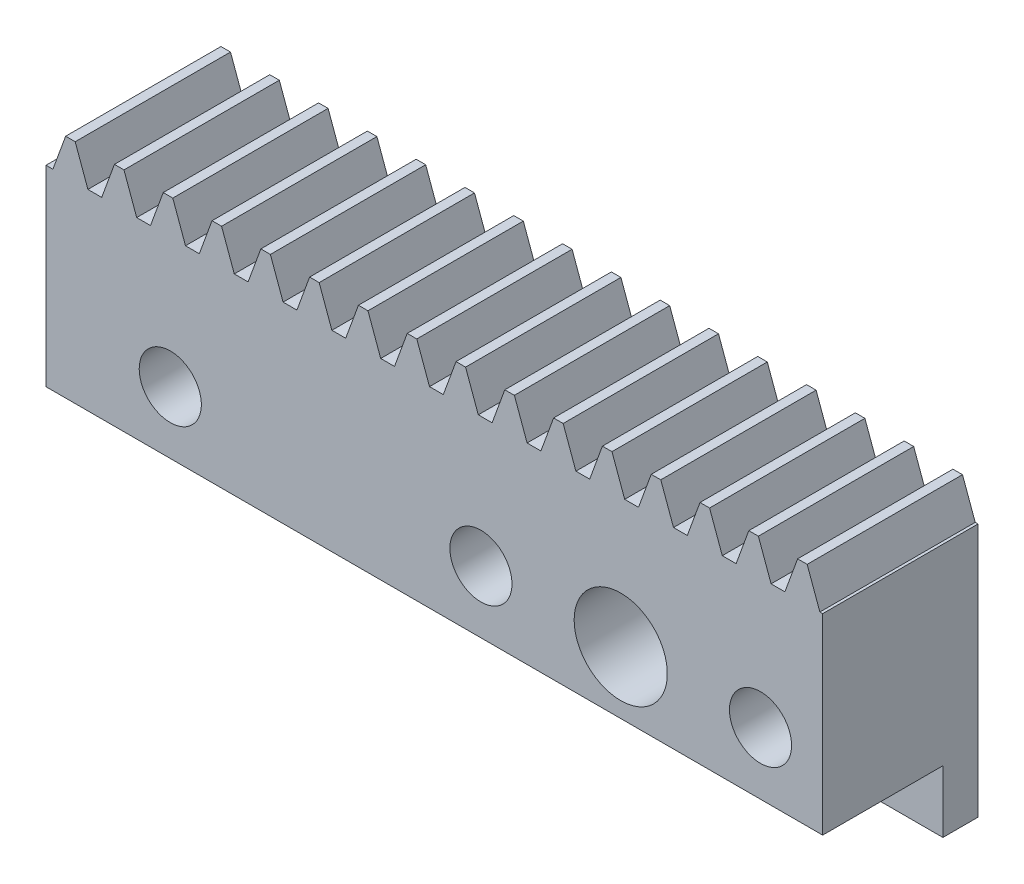
from build123d import *

# Parameters (mm, degrees)
BLANKSKE_W          = 25
BLANKSKE_H          = 7.3
BLANK_DEPTH         = 4
TOOTHCUTSIM_DEPTH   = 27.349383294
TEETHCUTS_COUNT     = 17
TEETHCUTS_PITCH     = 1.570796325
SKETCH4_W           = 25
SKETCH4_H           = 1.13
BOSS_EXTRUDE1_DEPTH = 2
BOSS_EXTRUDE2_DEPTH = 1
CUT_EXTRUDE1_DEPTH  = 27.519615382


with BuildPart() as part:
    # BlankSke → Blank (new body)
    with BuildSketch(Plane.XY):
        with Locations((12.5, 3.65)):
            Rectangle(BLANKSKE_W, BLANKSKE_H)
    extrude(amount=-BLANK_DEPTH)

    # TooCutSkeSim → ToothCutSim (cut, through all)
    with BuildSketch(Plane.XY):
        Polygon((0.222217685, 6.175), (-0.222217685, 6.175), (-0.640929042, 7.3254), (0.640929042, 7.3254), align=None)
    toothcutsim = extrude(amount=-TOOTHCUTSIM_DEPTH, mode=Mode.SUBTRACT)

    # TeethCuts: ToothCutSim ×17
    with Locations(*[(i * TEETHCUTS_PITCH, 0, 0) for i in range(1, TEETHCUTS_COUNT)]):
        add(toothcutsim, mode=Mode.SUBTRACT)

    # Sketch4 → Boss-Extrude1 (add)
    with BuildSketch(Plane.XZ):
        with Locations((12.5, -3.435)):
            Rectangle(SKETCH4_W, SKETCH4_H)
    extrude(amount=BOSS_EXTRUDE1_DEPTH)

    # Sketch7 → Boss-Extrude2 (add)
    with BuildSketch(Plane.XY):
        Polygon((25, 6.175), (24.910523515, 6.175), (24.501057002, 7.3), (24.193629073, 7.3), (23.78416256, 6.175), (23.33972719, 6.175), (22.930260677, 7.3), (22.622832748, 7.3), (22.213366235, 6.175), (21.768930865, 6.175), (21.359464352, 7.3), (21.052036423, 7.3), (20.64256991, 6.175), (20.19813454, 6.175), (19.788668027, 7.3), (19.481240098, 7.3), (19.071773585, 6.175), (18.627338215, 6.175), (18.217871702, 7.3), (17.910443773, 7.3), (17.50097726, 6.175), (17.05654189, 6.175), (16.647075377, 7.3), (16.339647448, 7.3), (15.930180935, 6.175), (15.485745565, 6.175), (15.076279052, 7.3), (14.768851123, 7.3), (14.35938461, 6.175), (13.91494924, 6.175), (13.505482727, 7.3), (13.198054798, 7.3), (12.788588285, 6.175), (12.344152915, 6.175), (11.934686402, 7.3), (11.627258473, 7.3), (11.21779196, 6.175), (10.77335659, 6.175), (10.363890077, 7.3), (10.056462148, 7.3), (9.646995635, 6.175), (9.202560265, 6.175), (8.793093752, 7.3), (8.485665823, 7.3), (8.07619931, 6.175), (7.63176394, 6.175), (7.222297427, 7.3), (6.914869498, 7.3), (6.505402985, 6.175), (6.060967615, 6.175), (5.651501102, 7.3), (5.344073173, 7.3), (4.93460666, 6.175), (4.49017129, 6.175), (4.080704777, 7.3), (3.773276848, 7.3), (3.363810335, 6.175), (2.919374965, 6.175), (2.509908452, 7.3), (2.202480523, 7.3), (1.79301401, 6.175), (1.34857864, 6.175), (0.939112127, 7.3), (0.631684198, 7.3), (0.222217685, 6.175), (0, 6.175), (0, 0), (25, 0), align=None)
    extrude(amount=BOSS_EXTRUDE2_DEPTH)

    # Sketch1 → Cut-Extrude1 (cut, through all)
    with BuildSketch(Plane(origin=(0, 0, -4), x_dir=(-1, 0, 0), z_dir=(0, 0, -1))):
        with BuildLine():
            Line((-23, 1), (-23, 2))
            Line((-23, 2), (-24, 2))
            ThreePointArc((-24, 2), (-23.707106781, 1.292893219), (-23, 1))
        make_face()
        with BuildLine():
            Line((-24, 2), (-23, 2))
            Line((-23, 2), (-23, 3))
            ThreePointArc((-23, 3), (-23.707106781, 2.707106781), (-24, 2))
        make_face()
        with BuildLine():
            Line((-23, 3), (-23, 2))
            Line((-23, 2), (-23, 1))
            ThreePointArc((-23, 1), (-22.292893219, 1.292893219), (-22, 2))
            ThreePointArc((-22, 2), (-22.292893219, 2.707106781), (-23, 3))
        make_face()
        with BuildLine():
            ThreePointArc((-17, 2), (-18.5, 3.5), (-20, 2))
            Line((-20, 2), (-17, 2))
        make_face()
        with BuildLine():
            Line((-17, 2), (-20, 2))
            ThreePointArc((-20, 2), (-18.5, 0.5), (-17, 2))
        make_face()
        with BuildLine():
            ThreePointArc((-13, 2), (-14, 3), (-15, 2))
            Line((-15, 2), (-13, 2))
        make_face()
        with BuildLine():
            Line((-13, 2), (-15, 2))
            ThreePointArc((-15, 2), (-14, 1), (-13, 2))
        make_face()
        with BuildLine():
            ThreePointArc((-3, 2), (-4, 3), (-5, 2))
            Line((-5, 2), (-3, 2))
        make_face()
        with BuildLine():
            Line((-3, 2), (-5, 2))
            ThreePointArc((-5, 2), (-4, 1), (-3, 2))
        make_face()
    extrude(amount=-CUT_EXTRUDE1_DEPTH, mode=Mode.SUBTRACT)


solid = part.part
